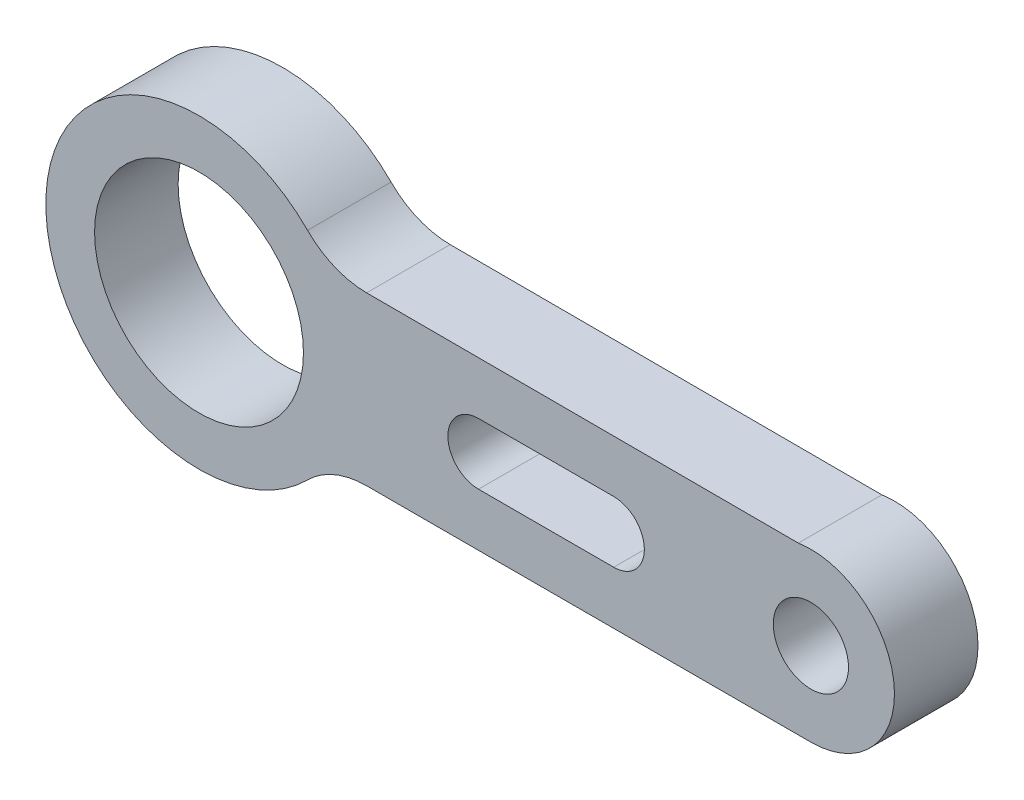
from build123d import *

# Parameters (mm, degrees)
ESQUISSE6_R        = 1.35
ESQUISSE6_R_2      = 3.75
BOSS_EXTRU_6_DEPTH = 3


with BuildPart() as part:
    # Esquisse6 → Boss.-Extru.6 (new body)
    with BuildSketch(Plane.XY):
        with BuildLine():
            Line((-3.987977269, 18.466237455), (-19.940968623, 18.463296912))
            ThreePointArc((-19.940968623, 18.463296912), (-21.090441726, 18.234116339), (-22.064368184, 17.581981843))
            ThreePointArc((-22.064368184, 17.581981843), (-31.458280506, 21.468938246), (-22.060555312, 25.346666961))
            ThreePointArc((-22.060555312, 25.346666961), (-21.088444228, 24.694065374), (-19.940566739, 24.46327096))
            Line((-19.940566739, 24.46327096), (-4.439636922, 24.432043174))
            ThreePointArc((-4.439636922, 24.432043174), (-0.996538054, 21.692713553), (-3.987977269, 18.466237455))
        make_face()
        with Locations((-3.987977269, 21.466237455)):
            Circle(ESQUISSE6_R, mode=Mode.SUBTRACT)
        with Locations((-25.958281169, 21.466237455)):
            Circle(ESQUISSE6_R_2, mode=Mode.SUBTRACT)
        with BuildLine():
            Line((-15.92195018, 22.566237455), (-11.068355584, 22.566237455))
            ThreePointArc((-11.068355584, 22.566237455), (-9.968355584, 21.466237455), (-11.068355584, 20.366237455))
            Line((-11.068355584, 20.366237455), (-15.92195018, 20.366237455))
            ThreePointArc((-15.92195018, 20.366237455), (-17.02195018, 21.466237455), (-15.92195018, 22.566237455))
        make_face(mode=Mode.SUBTRACT)
    extrude(amount=BOSS_EXTRU_6_DEPTH)


solid = part.part
